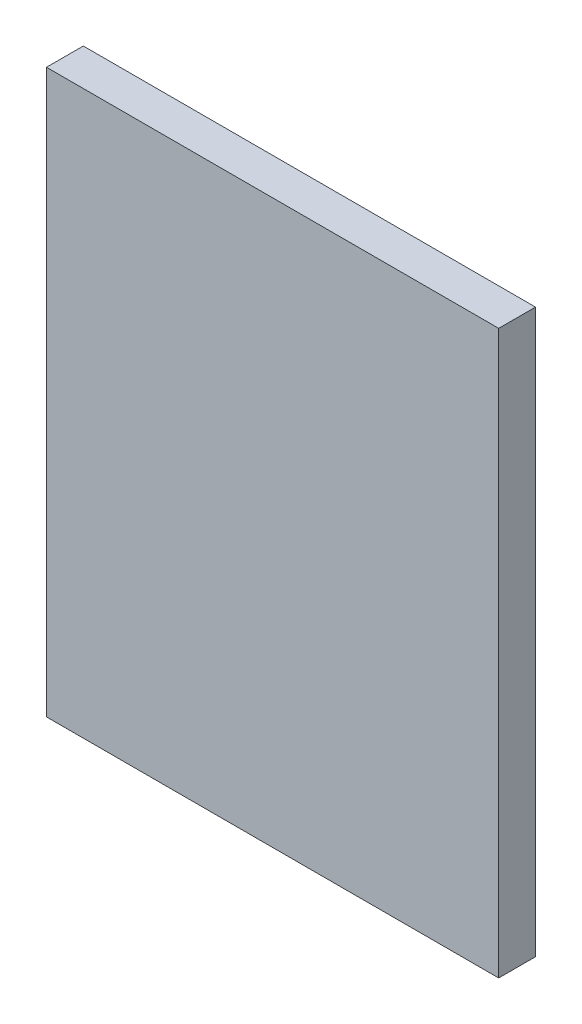
from build123d import *

# Parameters (mm, degrees)
IZIM1_W                     = 430
IZIM1_H                     = 535
Y_KSEKLIK_EKSTR_ZYON1_DEPTH = 35


with BuildPart() as part:
    # Çizim1 → Yükseklik-Ekstrüzyon1 (new body)
    with BuildSketch(Plane.XY):
        with Locations((145.989947256, 236.877099842)):
            Rectangle(IZIM1_W, IZIM1_H)
    extrude(amount=Y_KSEKLIK_EKSTR_ZYON1_DEPTH)


solid = part.part
